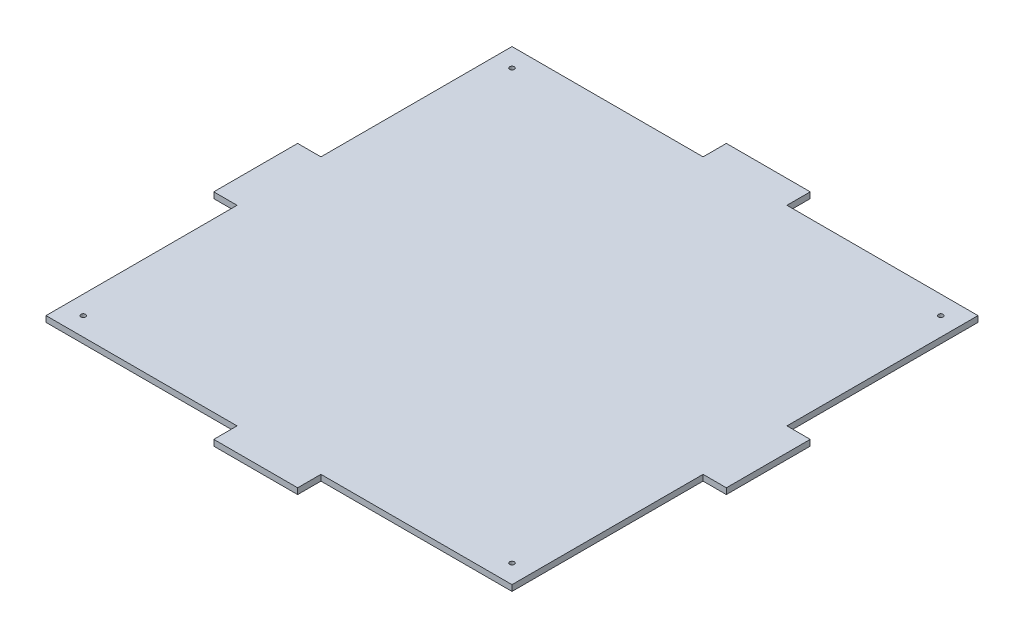
from build123d import *

# Parameters (mm, degrees)
SKETCH2_W              = 250
SKETCH2_H              = 250
BASE_DEPTH             = 3.175
SKETCH10_W             = 45
SKETCH10_H             = 3.175
JIGSAW1_DEPTH          = 12.5
SKETCH11_W             = 45
SKETCH11_H             = 3.175
JIGSAW2_DEPTH          = 12.5
SKETCH13_W             = 45
SKETCH13_H             = 3.175
JIGSAW3_DEPTH          = 12.5
SKETCH14_W             = 45
SKETCH14_H             = 3.175
JIGSAW4_DEPTH          = 12.5
STANDOFF_HOLES_D       = 2.5
SKETCH21_R             = 1.25
STANDOFF_HOLES_2_DEPTH = 10


with BuildPart() as part:
    # Sketch2 → Base (new body)
    with BuildSketch(Plane(origin=(0, 0, 0), x_dir=(1, 0, 0), z_dir=(0, 1, 0))):
        Rectangle(SKETCH2_W, SKETCH2_H)
    extrude(amount=BASE_DEPTH)

    # Sketch10 → Jigsaw1 (add)
    with BuildSketch(Plane(origin=(0, 0, -125), x_dir=(-1, 0, 0), z_dir=(0, 0, -1))):
        with Locations((0, 1.5875)):
            Rectangle(SKETCH10_W, SKETCH10_H)
    extrude(amount=JIGSAW1_DEPTH)

    # Sketch11 → Jigsaw2 (add)
    with BuildSketch(Plane.ZY.offset(125)):
        with Locations((0, 1.5875)):
            Rectangle(SKETCH11_W, SKETCH11_H)
    extrude(amount=JIGSAW2_DEPTH)

    # Sketch13 → Jigsaw3 (add)
    with BuildSketch(Plane.XY.offset(125)):
        with Locations((0, 1.5875)):
            Rectangle(SKETCH13_W, SKETCH13_H)
    extrude(amount=JIGSAW3_DEPTH)

    # Sketch14 → Jigsaw4 (add)
    with BuildSketch(Plane(origin=(125, 0, 0), x_dir=(0, 0, -1), z_dir=(1, 0, 0))):
        with Locations((0, 1.5875)):
            Rectangle(SKETCH14_W, SKETCH14_H)
    extrude(amount=JIGSAW4_DEPTH)

    # Standoff Holes (through all)
    with Locations(Plane(origin=(-115, 3.175, -115), x_dir=(0, 0, 1), z_dir=(0, 1, 0))):
        with Locations((0, 0)):
            Hole(STANDOFF_HOLES_D / 2)

    # Sketch21 → Standoff Holes 2 (cut)
    with BuildSketch(Plane(origin=(0, 3.175, 0), x_dir=(1, 0, 0), z_dir=(0, 1, 0))):
        with Locations((115, 115)):
            Circle(SKETCH21_R)
        with Locations((115, -115)):
            Circle(SKETCH21_R)
        with Locations((-115, -115)):
            Circle(SKETCH21_R)
    extrude(amount=-STANDOFF_HOLES_2_DEPTH, mode=Mode.SUBTRACT)


solid = part.part
